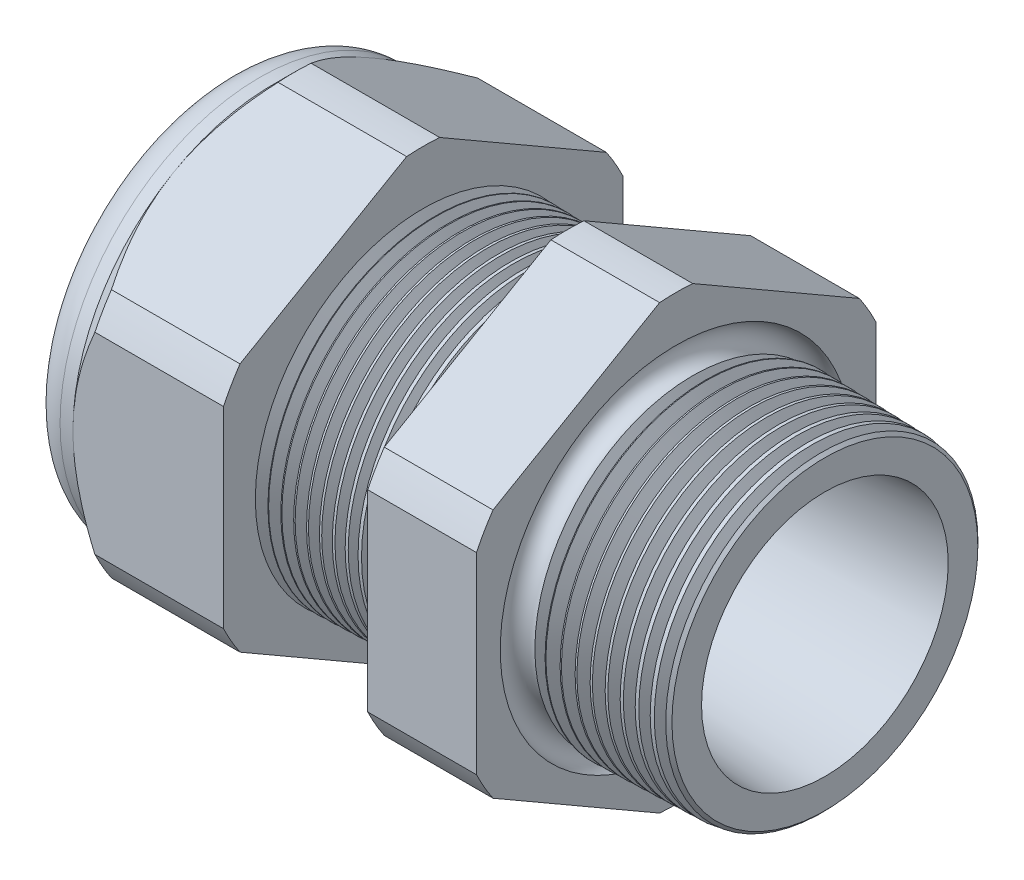
from build123d import *

# Parameters (mm, degrees)
SKETCH12_OUTSIDE_W = 65.04
SKETCH12_OUTSIDE_H = 65.04
CUT_EXTRUDE2_DEPTH = 34.014
FILLET4_R          = 2.032
SKETCH19_OUTSIDE_W = 39.986
SKETCH19_OUTSIDE_H = 42.612
SKETCH19_OUTSIDE_R = 11.938
CUT_EXTRUDE3_DEPTH = 1.999996
CUT_EXTRUDE3_DRAFT = -45
CHAMFER1_SIZE      = 0.260919487
CHAMFER1_SIZE2     = 0.254
SKETCH21_R         = 5.969
PLUG_DEPTH         = 6.35
SKETCH22_R         = 5.715
CUT_EXTRUDE4_DEPTH = 0.508
SKETCH27_R         = 2.159
PLUGHOLES_DEPTH    = 36.306
CIRPATTERN1_COUNT  = 2
LPATTERN1_COUNT    = 11
LPATTERN1_PITCH    = 0.762
LPATTERN2_COUNT    = 10
LPATTERN2_PITCH    = 0.889
SKETCH32_R         = 0.889


with BuildPart() as part:
    # Sketch10 → Revolve2 (revolve)
    with BuildSketch(Plane.XY, mode=Mode.PRIVATE) as revolve2_sk:
        Polygon((-34.798, 5.969), (-22.998, 5.969), (1.016, 7.372171279), (1.016, 9.404171279), (-7.874, 9.636964122), (-7.874, 23.876), (-14.374, 23.876), (-14.374, 9.807172612), (-22.998, 10.033), (-22.998, 23.876), (-31.998, 23.876), (-31.998, 11.938), (-34.798, 11.938), align=None)
    revolve(revolve2_sk.sketch.rotate(Axis((0, 0, 0), (-1, 0, 0)), 90), axis=Axis((0, 0, 0), (-1, 0, 0)))  # turned: the seam where the file's is

    # Sketch12 outside → Cut-Extrude2 (cut, through all)
    with BuildSketch(Plane.ZY.offset(31.998)):
        Rectangle(SKETCH12_OUTSIDE_W, SKETCH12_OUTSIDE_H)
        with BuildLine():
            Line((-0.98819228, 13.214281948), (-10.94980772, 7.462940592))
            ThreePointArc((-10.94980772, 7.462940592), (-11.47585851, 6.62559), (-11.938, 5.751341356))
            Line((-11.938, 5.751341356), (-11.938, -5.751341356))
            ThreePointArc((-11.938, -5.751341356), (-11.47585851, -6.62559), (-10.94980772, -7.462940592))
            Line((-10.94980772, -7.462940592), (-0.98819228, -13.214281948))
            ThreePointArc((-0.98819228, -13.214281948), (0, -13.25118), (0.98819228, -13.214281948))
            Line((0.98819228, -13.214281948), (10.94980772, -7.462940592))
            ThreePointArc((10.94980772, -7.462940592), (11.47585851, -6.62559), (11.938, -5.751341356))
            Line((11.938, -5.751341356), (11.938, 5.751341356))
            ThreePointArc((11.938, 5.751341356), (11.47585851, 6.62559), (10.94980772, 7.462940592))
            Line((10.94980772, 7.462940592), (0.98819228, 13.214281948))
            ThreePointArc((0.98819228, 13.214281948), (0, 13.25118), (-0.98819228, 13.214281948))
        make_face(mode=Mode.SUBTRACT)
    extrude(amount=-CUT_EXTRUDE2_DEPTH, mode=Mode.SUBTRACT)

    # Fillet4
    fillet4_edges = [part.edges().sort_by_distance(p)[0] for p in [
        (-34.798, 0, 11.938),
    ]]
    fillet(fillet4_edges, radius=FILLET4_R)


with BuildPart() as cut_extrude3_tool:
    # Sketch19 outside → Cut-Extrude3 (with draft: the straight prism first)
    with BuildSketch(Plane.ZY.offset(31.998)):
        Rectangle(SKETCH19_OUTSIDE_W, SKETCH19_OUTSIDE_H)
        Circle(SKETCH19_OUTSIDE_R, mode=Mode.SUBTRACT)
    extrude(amount=-CUT_EXTRUDE3_DEPTH)
    # Cut-Extrude3: the draft: its side faces are tilted about the plane it starts from
    cut_extrude3_sides = [cut_extrude3_tool.faces().sort_by_distance(p)[0] for p in [
        (-30.998002, -21.306, 0),
        (-30.998002, 0, 19.993),
        (-30.998002, 21.306, 0),
        (-30.998002, 0, -19.993),
        (-30.998002, 0, -11.938),
    ]]
    draft(cut_extrude3_sides, Plane.ZY.offset(31.998), CUT_EXTRUDE3_DRAFT)


with BuildPart() as part_1:
    add(part.part)

    # Cut-Extrude3: cut by cut_extrude3_tool
    add(cut_extrude3_tool.part, mode=Mode.SUBTRACT)

    # Chamfer1
    chamfer1_edges = [part_1.edges().sort_by_distance(p)[0] for p in [
        (1.016, 0, 9.404171279),
    ]]
    chamfer1_side = [part_1.faces().sort_by_distance(p)[0] for p in [
        (1.016, 0, 7.638161411),
    ]]
    chamfer(chamfer1_edges, length=CHAMFER1_SIZE, length2=CHAMFER1_SIZE2, reference=chamfer1_side[0])

    # Sketch29 → Cut-Revolve1 (revolve, cut)
    with BuildSketch(Plane.XY, mode=Mode.PRIVATE) as cut_revolve1_sk:
        Polygon((-22.998, 10.033), (-22.265016419, 10.013806149), (-22.648130572, 9.388620673), align=None)
    cut_revolve1 = revolve(cut_revolve1_sk.sketch.rotate(Axis((0, 0, 0), (-1, 0, 0)), 90), axis=Axis((0, 0, 0), (-1, 0, 0)), mode=Mode.SUBTRACT)  # turned: the seam where the file's is

    # LPattern1: Cut-Revolve1 ×11
    with Locations(*[(i * LPATTERN1_PITCH, 0, 0) for i in range(1, LPATTERN1_COUNT)]):
        add(cut_revolve1, mode=Mode.SUBTRACT)

    # Sketch30 → Cut-Revolve2 (revolve, cut)
    with BuildSketch(Plane.XY, mode=Mode.PRIVATE) as cut_revolve2_sk:
        Polygon((-7.874, 9.636964122), (-6.994419703, 9.613931502), (-7.454156686, 8.86370893), align=None)
    cut_revolve2 = revolve(cut_revolve2_sk.sketch.rotate(Axis((0, 0, 0), (-1, 0, 0)), 270), axis=Axis((0, 0, 0), (-1, 0, 0)), mode=Mode.SUBTRACT)  # turned: the seam where the file's is

    # LPattern2: Cut-Revolve2 ×10
    with Locations(*[(i * LPATTERN2_PITCH, 0, 0) for i in range(1, LPATTERN2_COUNT)]):
        add(cut_revolve2, mode=Mode.SUBTRACT)

    # Sketch32 → Cut-Revolve3 (revolve, cut)
    with BuildSketch(Plane.XY, mode=Mode.PRIVATE) as cut_revolve3_sk:
        with Locations((-7.747, 9.636964122)):
            Circle(SKETCH32_R)
    revolve(cut_revolve3_sk.sketch.rotate(Axis((0, 0, 0), (-1, 0, 0)), 270), axis=Axis((0, 0, 0), (-1, 0, 0)), mode=Mode.SUBTRACT)  # turned: the seam where the file's is


with BuildPart() as body_2:
    # Sketch21 → plug (new body)
    with BuildSketch(Plane.ZY.offset(34.798)):
        Circle(SKETCH21_R)
    extrude(amount=-PLUG_DEPTH)

    # Sketch22 → Cut-Extrude4 (cut)
    with BuildSketch(Plane.ZY.offset(34.798)):
        Circle(SKETCH22_R)
    extrude(amount=-CUT_EXTRUDE4_DEPTH, mode=Mode.SUBTRACT)

    # Sketch27 → plugholes (cut, through all)
    with BuildSketch(Plane.ZY.offset(34.29)):
        with Locations((-3.547364, 0)):
            Circle(SKETCH27_R)
    plugholes = extrude(amount=-PLUGHOLES_DEPTH, mode=Mode.SUBTRACT)

    # CirPattern1: plugholes ×2 about axis
    cirpattern1_axis = Axis((0, 0, 0), (1, 0, 0))
    for i in range(1, CIRPATTERN1_COUNT):
        add(plugholes.rotate(cirpattern1_axis, i * 360 / CIRPATTERN1_COUNT), mode=Mode.SUBTRACT)


solid = Compound([part_1.part, body_2.part])
